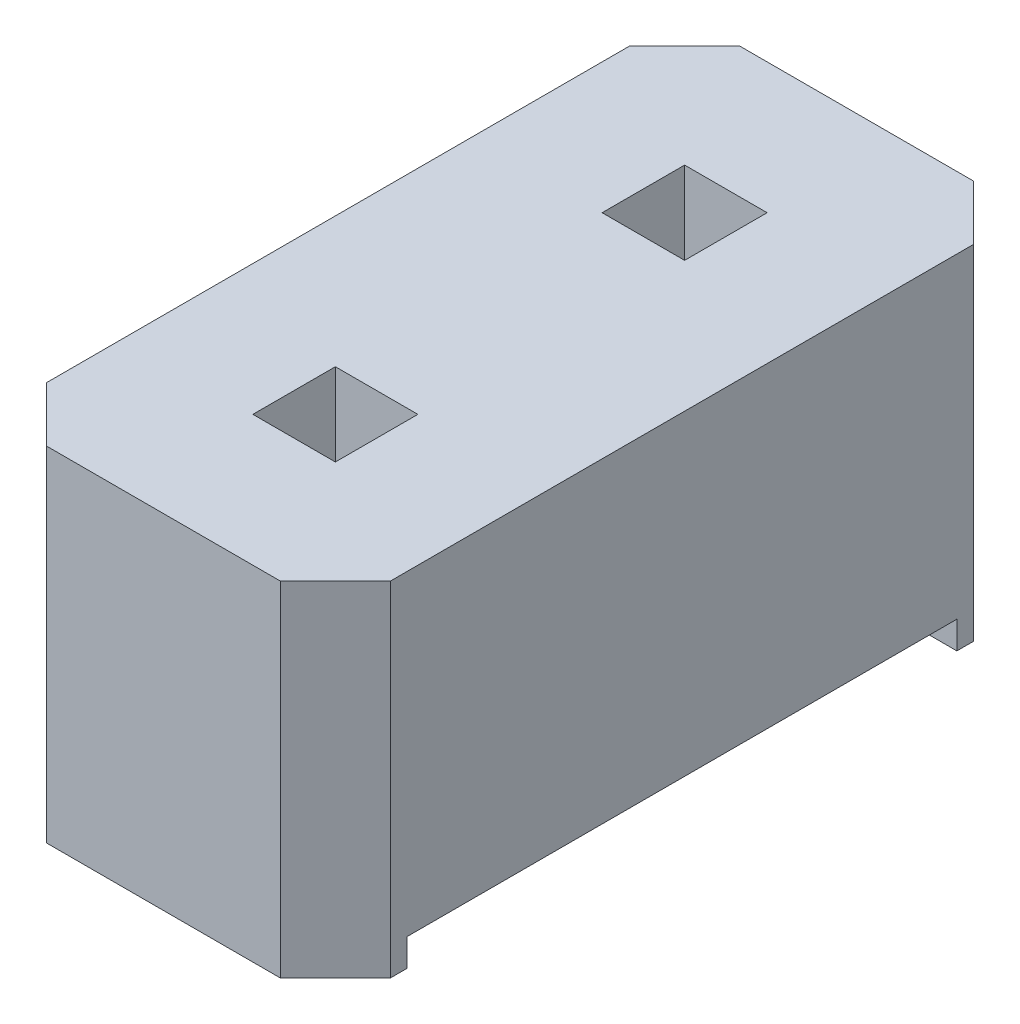
from build123d import *

# Parameters (mm, degrees)
ESQUISSE1_W             = 0.6
ESQUISSE1_H             = 0.6
BOSS_EXTRU_1_DEPTH      = 2.5
ESQUISSE2_W             = 4
ESQUISSE2_H             = 0.4
ENL_V_MAT_EXTRU_1_DEPTH = 3.5


with BuildPart() as part:
    # Esquisse1 → Boss.-Extru.1 (new body)
    with BuildSketch(Plane(origin=(0, 0, 0), x_dir=(1, 0, 0), z_dir=(0, 1, 0))):
        Polygon((-1.25, 2.12), (-0.85, 2.52), (0.85, 2.52), (1.25, 2.12), (1.25, -2.12), (0.85, -2.52), (-0.85, -2.52), (-1.25, -2.12), align=None)
        with Locations((0, -1.27)):
            Rectangle(ESQUISSE1_W, ESQUISSE1_H, mode=Mode.SUBTRACT)
        with Locations((0, 1.27)):
            Rectangle(ESQUISSE1_W, ESQUISSE1_H, mode=Mode.SUBTRACT)
    extrude(amount=BOSS_EXTRU_1_DEPTH)

    # Esquisse2 → Enlèv. mat.-Extru.1 (cut, through all)
    with BuildSketch(Plane.ZY.offset(1.25)):
        Rectangle(ESQUISSE2_W, ESQUISSE2_H)
    extrude(amount=-ENL_V_MAT_EXTRU_1_DEPTH, mode=Mode.SUBTRACT)


solid = part.part
